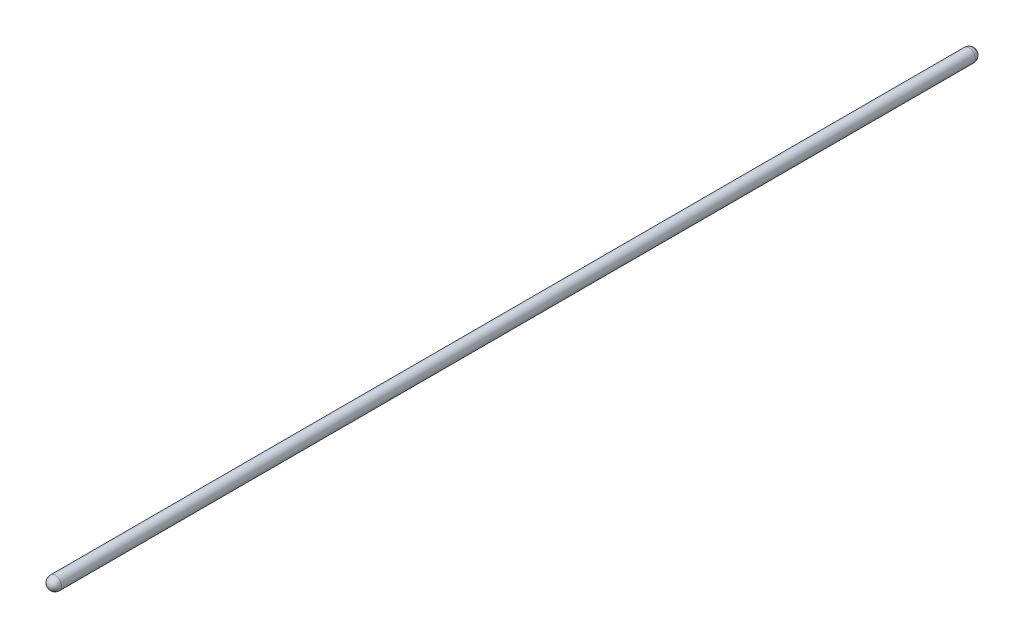
from build123d import *


with BuildPart() as part:
    # Sketch1 → Revolve1 (revolve)
    with BuildSketch(Plane(origin=(0, 0, 0), x_dir=(1, 0, 0), z_dir=(0, 1, 0))):
        with BuildLine():
            Line((9.525, 0), (9.525, -1346.344018))
            ThreePointArc((9.525, -1346.344018), (6.735192091, -1353.079210091), (0, -1355.869018))
            Line((0, -1355.869018), (0, 9.525))
            ThreePointArc((0, 9.525), (6.735192091, 6.735192091), (9.525, 0))
        make_face()
    revolve(axis=Axis((0, 0, -9.525), (0, 0, 1)))


solid = part.part
